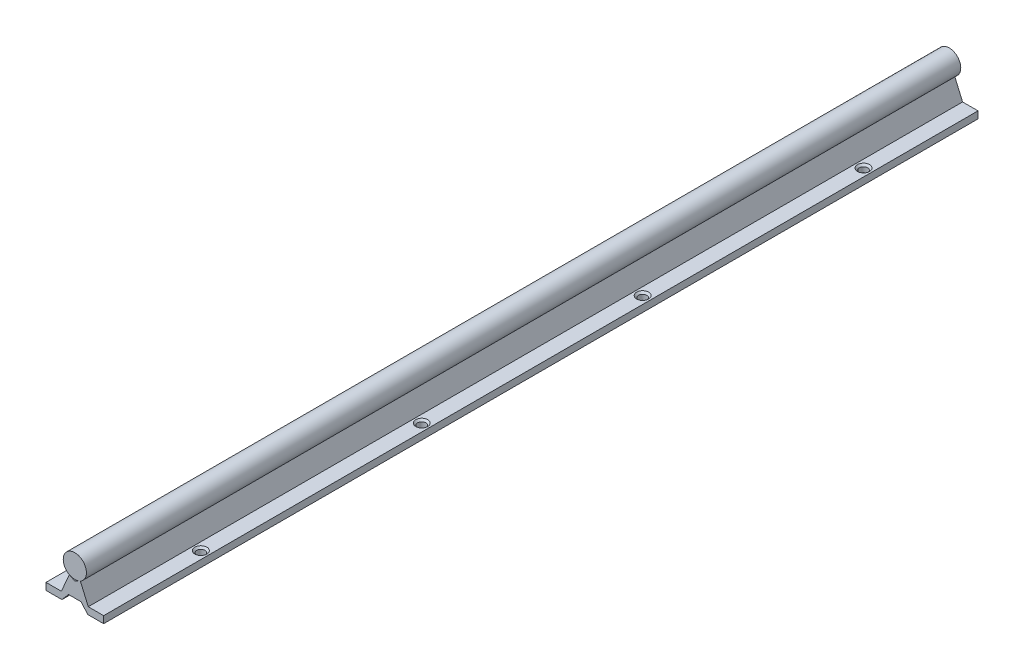
from build123d import *

# Parameters (mm, degrees)
SKETCH1_R           = 8.001
BOSS_EXTRUDE1_DEPTH = 301.625
SKETCH5_R           = 2.8702
CUT_EXTRUDE1_DEPTH  = 5.826
CHAMFER1_SIZE       = 1.27


with BuildPart() as part:
    # Sketch1 → Boss-Extrude1 (new body, symmetric)
    with BuildSketch(Plane.XY):
        with Locations((0, 9.017)):
            Circle(SKETCH1_R)
        Polygon((-19.8882, -15.494), (-8.89, -15.494), (-4.3688, -10.16), (4.3688, -10.16), (8.89, -15.494), (19.8882, -15.494), (19.8882, -10.668), (9.271, -10.668), (3.81, 1.981383396), (0, 0), (-3.81, 1.981383396), (-9.271, -10.668), (-19.8882, -10.668), align=None)
    extrude(amount=BOSS_EXTRUDE1_DEPTH, both=True)

    # Sketch5 → Cut-Extrude1 (cut, through all)
    with BuildSketch(Plane(origin=(0, -10.668, 0), x_dir=(1, 0, 0), z_dir=(0, 1, 0))):
        with Locations((14.5796, -229.235)):
            Circle(SKETCH5_R)
        with Locations((-14.5796, -229.235)):
            Circle(SKETCH5_R)
        with Locations((-14.5796, -76.835)):
            Circle(SKETCH5_R)
        with Locations((14.5796, -76.835)):
            Circle(SKETCH5_R)
        with Locations((-14.5796, 75.565)):
            Circle(SKETCH5_R)
        with Locations((14.5796, 75.565)):
            Circle(SKETCH5_R)
        with Locations((-14.5796, 227.965)):
            Circle(SKETCH5_R)
        with Locations((14.5796, 227.965)):
            Circle(SKETCH5_R)
    extrude(amount=-CUT_EXTRUDE1_DEPTH, mode=Mode.SUBTRACT)

    # Chamfer1
    chamfer1_edges = [part.edges().sort_by_distance(p)[0] for p in [
        (11.7094, -10.668, -75.565),
        (-17.4498, -10.668, 76.835),
        (11.7094, -10.668, 76.835),
        (-17.4498, -10.668, 229.235),
        (-17.4498, -10.668, -227.965),
        (11.7094, -10.668, -227.965),
        (-17.4498, -10.668, -75.565),
        (11.7094, -10.668, 229.235),
    ]]
    chamfer(chamfer1_edges, length=CHAMFER1_SIZE)


solid = part.part
